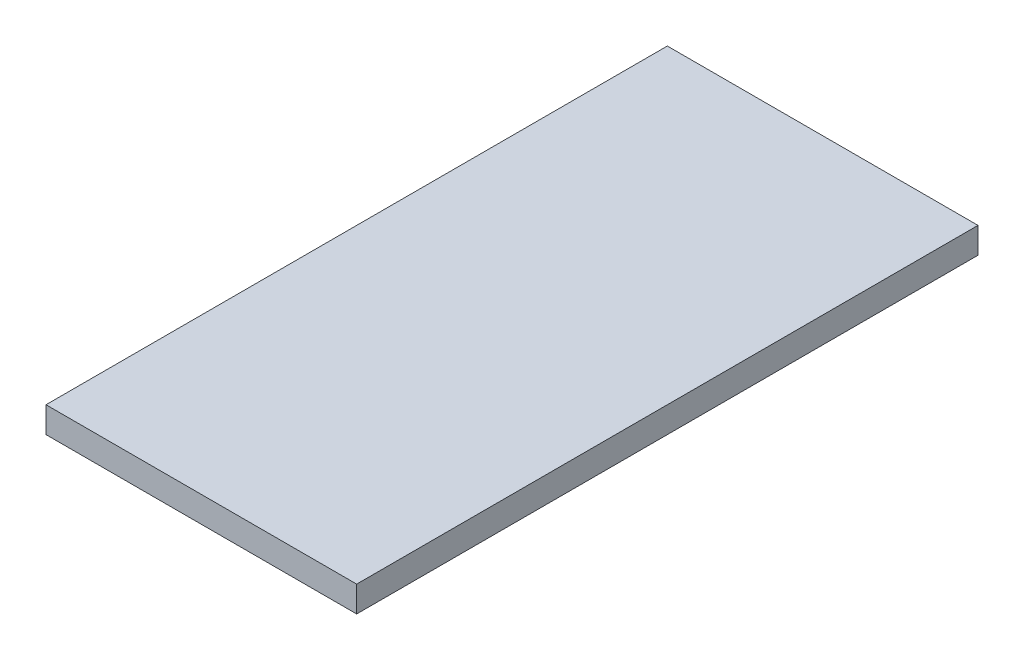
from build123d import *

# Parameters (mm, degrees)
SKETCH1_W           = 120
SKETCH1_H           = 240
BOSS_EXTRUDE1_DEPTH = 10


with BuildPart() as part:
    # Sketch1 → Boss-Extrude1 (new body)
    with BuildSketch(Plane(origin=(0, 0, 0), x_dir=(1, 0, 0), z_dir=(0, 1, 0))):
        with Locations((60, 120)):
            Rectangle(SKETCH1_W, SKETCH1_H)
    extrude(amount=BOSS_EXTRUDE1_DEPTH)


solid = part.part
